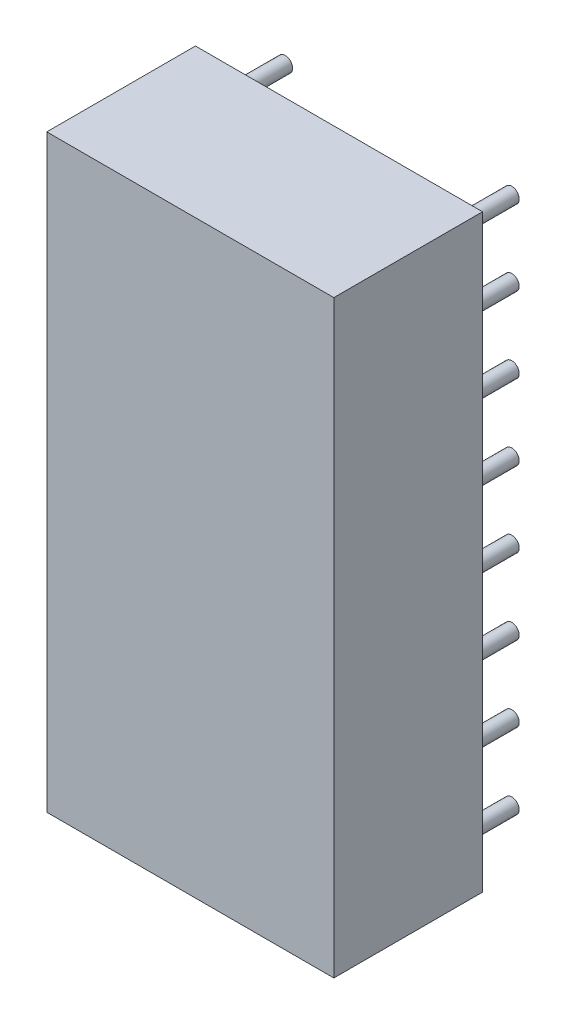
from build123d import *

# Parameters (mm, degrees)
SKETCH1_W               = 9.652
SKETCH1_H               = 19.812
COMPONENT_OUTLINE_DEPTH = 5
SKETCH2_R               = 0.25
EXTRUDE_1_DEPTH         = 2
SKETCH3_R               = 0.25
EXTRUDE_2_DEPTH         = 2
SKETCH4_R               = 0.25
EXTRUDE_3_DEPTH         = 2
SKETCH5_R               = 0.25
EXTRUDE_4_DEPTH         = 2
SKETCH6_R               = 0.25
EXTRUDE_5_DEPTH         = 2
SKETCH7_R               = 0.25
EXTRUDE_6_DEPTH         = 2
SKETCH8_R               = 0.25
EXTRUDE_7_DEPTH         = 2
SKETCH9_R               = 0.25
EXTRUDE_8_DEPTH         = 2
SKETCH10_R              = 0.25
EXTRUDE_9_DEPTH         = 2
SKETCH11_R              = 0.25
EXTRUDE_10_DEPTH        = 2
SKETCH12_R              = 0.25
EXTRUDE_11_DEPTH        = 2
SKETCH13_R              = 0.25
EXTRUDE_12_DEPTH        = 2
SKETCH14_R              = 0.25
EXTRUDE_13_DEPTH        = 2
SKETCH15_R              = 0.25
EXTRUDE_14_DEPTH        = 2
SKETCH16_R              = 0.25
EXTRUDE_15_DEPTH        = 2
SKETCH17_R              = 0.25
EXTRUDE_16_DEPTH        = 2


with BuildPart() as part:
    # Sketch1 → Component_Outline (new body)
    with BuildSketch(Plane.XY):
        with Locations((5.08, 10.16)):
            Rectangle(SKETCH1_W, SKETCH1_H)
    extrude(amount=COMPONENT_OUTLINE_DEPTH)


with BuildPart() as body_2:
    # Sketch2 → Extrude 1 (new body)
    with BuildSketch(Plane.XY):
        with Locations((1.27, 1.27)):
            Circle(SKETCH2_R)
    extrude(amount=-EXTRUDE_1_DEPTH)


with BuildPart() as body_3:
    # Sketch3 → Extrude 2 (new body)
    with BuildSketch(Plane.XY):
        with Locations((1.27, 3.81)):
            Circle(SKETCH3_R)
    extrude(amount=-EXTRUDE_2_DEPTH)


with BuildPart() as body_4:
    # Sketch4 → Extrude 3 (new body)
    with BuildSketch(Plane.XY):
        with Locations((1.27, 6.35)):
            Circle(SKETCH4_R)
    extrude(amount=-EXTRUDE_3_DEPTH)


with BuildPart() as body_5:
    # Sketch5 → Extrude 4 (new body)
    with BuildSketch(Plane.XY):
        with Locations((1.27, 8.89)):
            Circle(SKETCH5_R)
    extrude(amount=-EXTRUDE_4_DEPTH)


with BuildPart() as body_6:
    # Sketch6 → Extrude 5 (new body)
    with BuildSketch(Plane.XY):
        with Locations((1.27, 11.43)):
            Circle(SKETCH6_R)
    extrude(amount=-EXTRUDE_5_DEPTH)


with BuildPart() as body_7:
    # Sketch7 → Extrude 6 (new body)
    with BuildSketch(Plane.XY):
        with Locations((1.27, 13.97)):
            Circle(SKETCH7_R)
    extrude(amount=-EXTRUDE_6_DEPTH)


with BuildPart() as body_8:
    # Sketch8 → Extrude 7 (new body)
    with BuildSketch(Plane.XY):
        with Locations((1.27, 16.51)):
            Circle(SKETCH8_R)
    extrude(amount=-EXTRUDE_7_DEPTH)


with BuildPart() as body_9:
    # Sketch9 → Extrude 8 (new body)
    with BuildSketch(Plane.XY):
        with Locations((1.27, 19.05)):
            Circle(SKETCH9_R)
    extrude(amount=-EXTRUDE_8_DEPTH)


with BuildPart() as body_10:
    # Sketch10 → Extrude 9 (new body)
    with BuildSketch(Plane.XY):
        with Locations((8.89, 1.27)):
            Circle(SKETCH10_R)
    extrude(amount=-EXTRUDE_9_DEPTH)


with BuildPart() as body_11:
    # Sketch11 → Extrude 10 (new body)
    with BuildSketch(Plane.XY):
        with Locations((8.89, 3.81)):
            Circle(SKETCH11_R)
    extrude(amount=-EXTRUDE_10_DEPTH)


with BuildPart() as body_12:
    # Sketch12 → Extrude 11 (new body)
    with BuildSketch(Plane.XY):
        with Locations((8.89, 6.35)):
            Circle(SKETCH12_R)
    extrude(amount=-EXTRUDE_11_DEPTH)


with BuildPart() as body_13:
    # Sketch13 → Extrude 12 (new body)
    with BuildSketch(Plane.XY):
        with Locations((8.89, 8.89)):
            Circle(SKETCH13_R)
    extrude(amount=-EXTRUDE_12_DEPTH)


with BuildPart() as body_14:
    # Sketch14 → Extrude 13 (new body)
    with BuildSketch(Plane.XY):
        with Locations((8.89, 11.43)):
            Circle(SKETCH14_R)
    extrude(amount=-EXTRUDE_13_DEPTH)


with BuildPart() as body_15:
    # Sketch15 → Extrude 14 (new body)
    with BuildSketch(Plane.XY):
        with Locations((8.89, 13.97)):
            Circle(SKETCH15_R)
    extrude(amount=-EXTRUDE_14_DEPTH)


with BuildPart() as body_16:
    # Sketch16 → Extrude 15 (new body)
    with BuildSketch(Plane.XY):
        with Locations((8.89, 16.51)):
            Circle(SKETCH16_R)
    extrude(amount=-EXTRUDE_15_DEPTH)


with BuildPart() as body_17:
    # Sketch17 → Extrude 16 (new body)
    with BuildSketch(Plane.XY):
        with Locations((8.89, 19.05)):
            Circle(SKETCH17_R)
    extrude(amount=-EXTRUDE_16_DEPTH)


solid = Compound([part.part, body_2.part, body_3.part, body_4.part, body_5.part, body_6.part, body_7.part, body_8.part, body_9.part, body_10.part, body_11.part, body_12.part, body_13.part, body_14.part, body_15.part, body_16.part, body_17.part])
